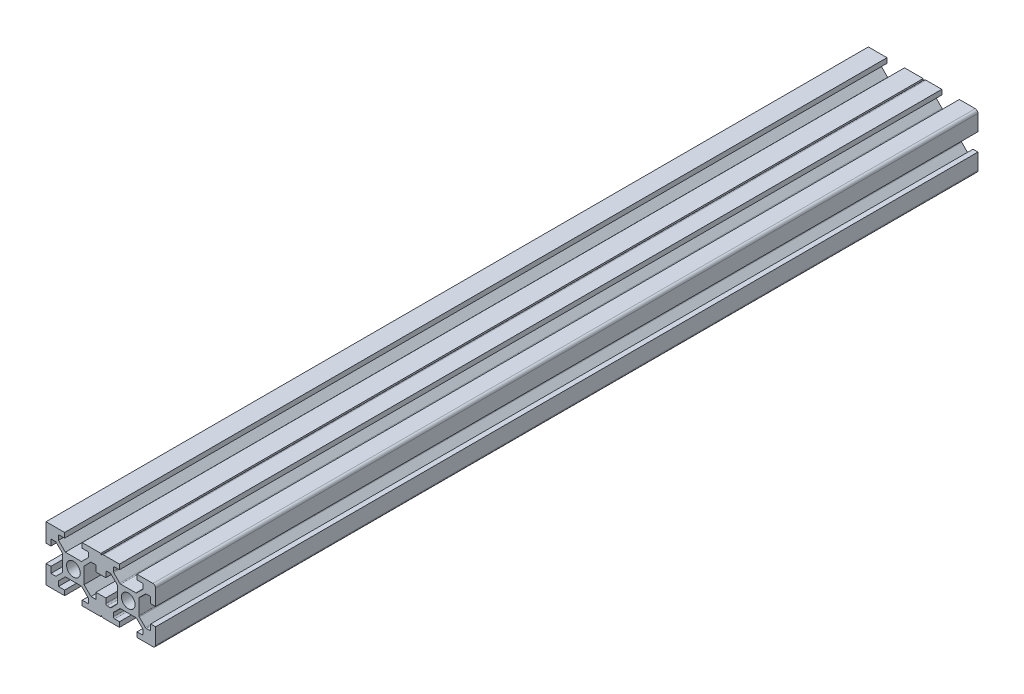
from build123d import *

# Parameters (mm, degrees)
SKETCH1_R           = 2.5
BOSS_EXTRUDE1_DEPTH = 300
FILLET1_R           = 1
FILLET2_R           = 0.5
FILLET3_R           = 0.5
FILLET4_R           = 0.5
FILLET5_R           = 0.5


with BuildPart() as part:
    # Sketch1 → Boss-Extrude1 (new body)
    with BuildSketch(Plane.XY):
        Polygon((13.2, 0), (13.2, 1.8), (15.45, 1.8), (15.45, 3.6), (12.95, 6.1), (7.05, 6.1), (4.55, 3.6), (4.55, 1.8), (6.8, 1.8), (6.8, 0), (0, 0), (0, 6.8), (1.8, 6.8), (1.8, 4.55), (3.6, 4.55), (6.1, 7.05), (6.1, 12.95), (3.6, 15.45), (1.8, 15.45), (1.8, 13.2), (0, 13.2), (0, 20), (6.8, 20), (6.8, 18.2), (4.55, 18.2), (4.55, 16.4), (7.05, 13.9), (12.95, 13.9), (15.45, 16.4), (15.45, 18.2), (13.2, 18.2), (13.2, 20), (20, 20), (20, 13.2), (18.2, 13.2), (18.2, 15.45), (16.4, 15.45), (13.9, 12.95), (13.9, 7.05), (16.4, 4.55), (18.2, 4.55), (18.2, 6.8), (20, 6.8), (20, 0), align=None)
        with Locations((10, 10)):
            Circle(SKETCH1_R, mode=Mode.SUBTRACT)
    boss_extrude1 = extrude(amount=BOSS_EXTRUDE1_DEPTH)

    # Fillet1
    fillet1_edges = [part.edges().sort_by_distance(p)[0] for p in [
        (0, 0, 150),
        (0, 20, 150),
        (20, 20, 150),
        (20, 0, 150),
    ]]
    fillet(fillet1_edges, radius=FILLET1_R)

    # Fillet2
    fillet2_edges = [part.edges().sort_by_distance(p)[0] for p in [
        (4.55, 18.2, 150),
        (4.55, 16.4, 150),
        (7.05, 13.9, 150),
        (12.95, 13.9, 150),
        (15.45, 16.4, 150),
        (15.45, 18.2, 150),
    ]]
    fillet(fillet2_edges, radius=FILLET2_R)

    # Fillet3
    fillet3_edges = [part.edges().sort_by_distance(p)[0] for p in [
        (18.2, 15.45, 150),
        (16.4, 15.45, 150),
        (13.9, 12.95, 150),
        (13.9, 7.05, 150),
        (16.4, 4.55, 150),
        (18.2, 4.55, 150),
    ]]
    fillet(fillet3_edges, radius=FILLET3_R)

    # Fillet4
    fillet4_edges = [part.edges().sort_by_distance(p)[0] for p in [
        (1.8, 4.55, 150),
        (3.6, 4.55, 150),
        (6.1, 7.05, 150),
        (6.1, 12.95, 150),
        (3.6, 15.45, 150),
        (1.8, 15.45, 150),
    ]]
    fillet(fillet4_edges, radius=FILLET4_R)

    # Fillet5
    fillet5_edges = [part.edges().sort_by_distance(p)[0] for p in [
        (15.45, 1.8, 150),
        (15.45, 3.6, 150),
        (12.95, 6.1, 150),
        (7.05, 6.1, 150),
        (4.55, 3.6, 150),
        (4.55, 1.8, 150),
    ]]
    fillet(fillet5_edges, radius=FILLET5_R)

    # Mirror1: Boss-Extrude1 across plane
    add(boss_extrude1.mirror(Plane(origin=(0, 0, 0), x_dir=(0, 0, 1), z_dir=(1, 0, 0))))


solid = part.part
